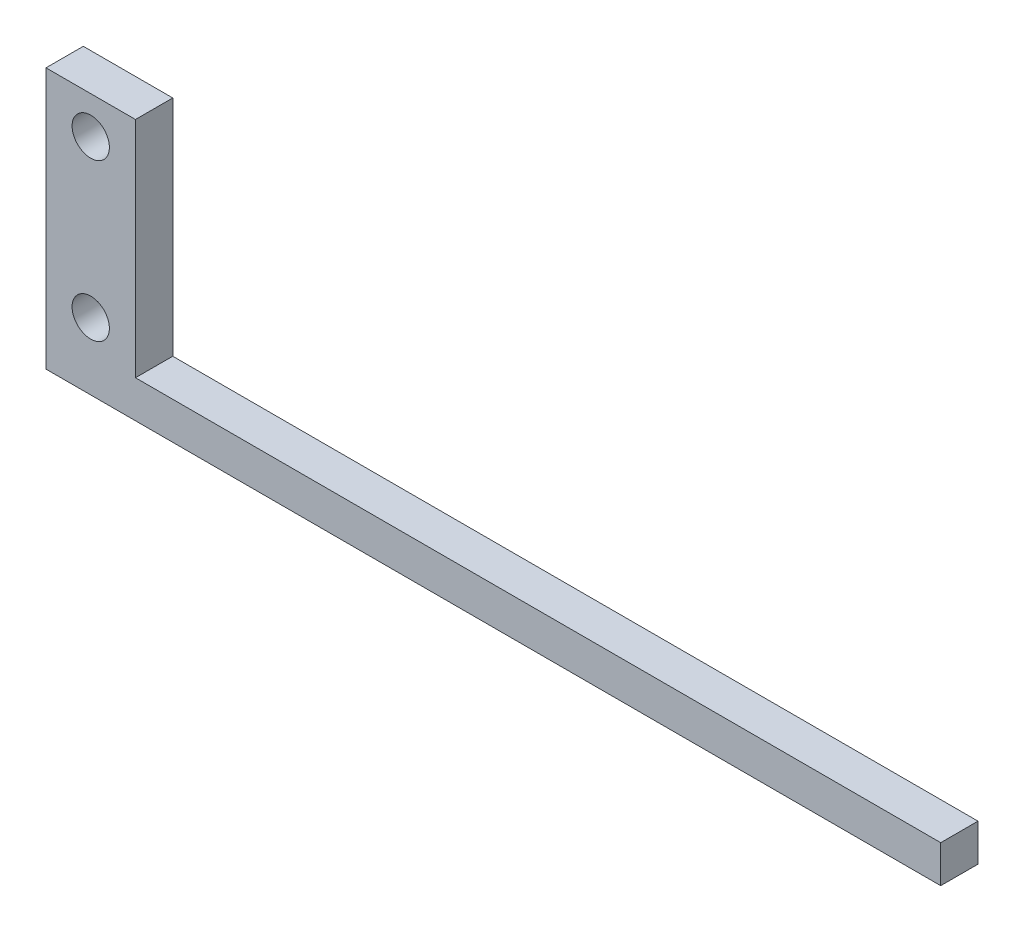
from build123d import *

# Parameters (mm, degrees)
BOSS_EXTRUDE1_DEPTH         = 6.35
F_1_4_0_25_DIAMETER_HOLE1_D = 6.35


with BuildPart() as part:
    # Sketch1 → Boss-Extrude1 (new body)
    with BuildSketch(Plane.XY):
        Polygon((0, 0), (0, 38.1), (-15.24, 38.1), (-15.24, -6.35), (137.16, -6.35), (137.16, 0), align=None)
    extrude(amount=BOSS_EXTRUDE1_DEPTH)

    # 1/4 (0.25) Diameter Hole1 (through all)
    with Locations(Plane(origin=(-7.62, 31.75, 0), x_dir=(-1, 0, 0), z_dir=(0, 0, -1))):
        with Locations((0, 0), (0, -26.689285954)):
            Hole(F_1_4_0_25_DIAMETER_HOLE1_D / 2)


solid = part.part
